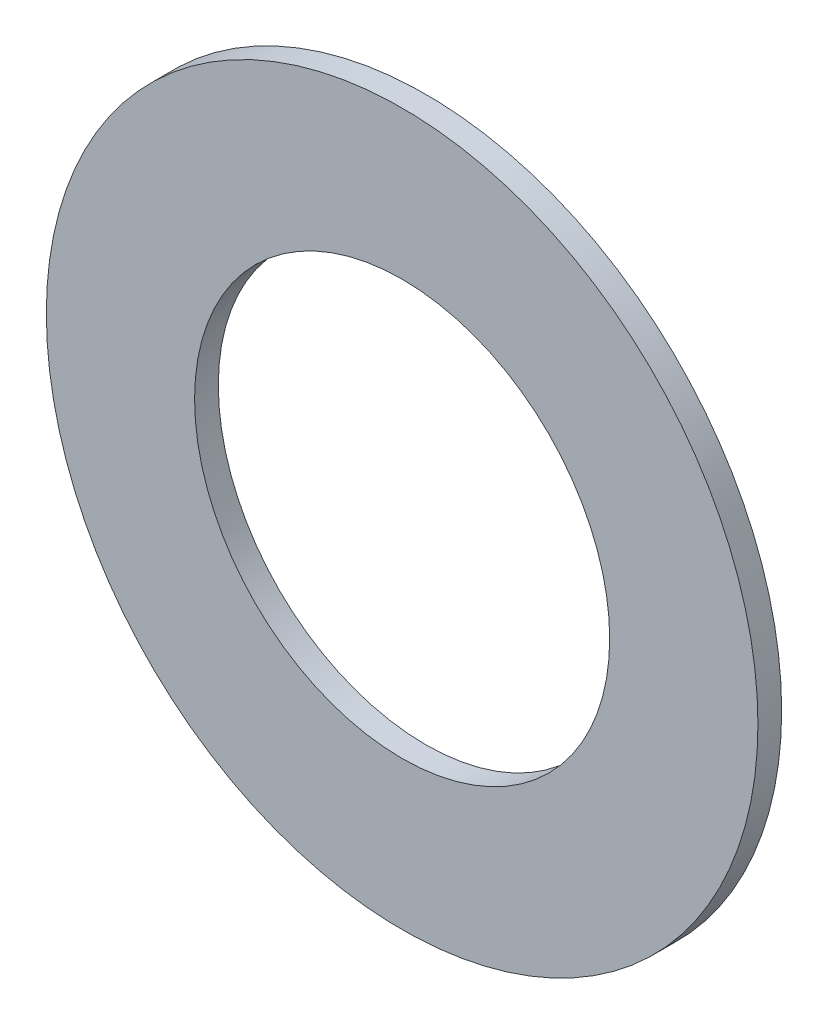
from build123d import *

# Parameters (mm, degrees)
SKETCH_1_R      = 15
SKETCH_1_R_2    = 8.75
EXTRUDE_1_DEPTH = 1


with BuildPart() as part:
    # 草图1 → 凸台-拉伸1 (new body)
    with BuildSketch(Plane.XY):
        Circle(SKETCH_1_R)
        Circle(SKETCH_1_R_2, mode=Mode.SUBTRACT)
    extrude(amount=EXTRUDE_1_DEPTH)


solid = part.part
